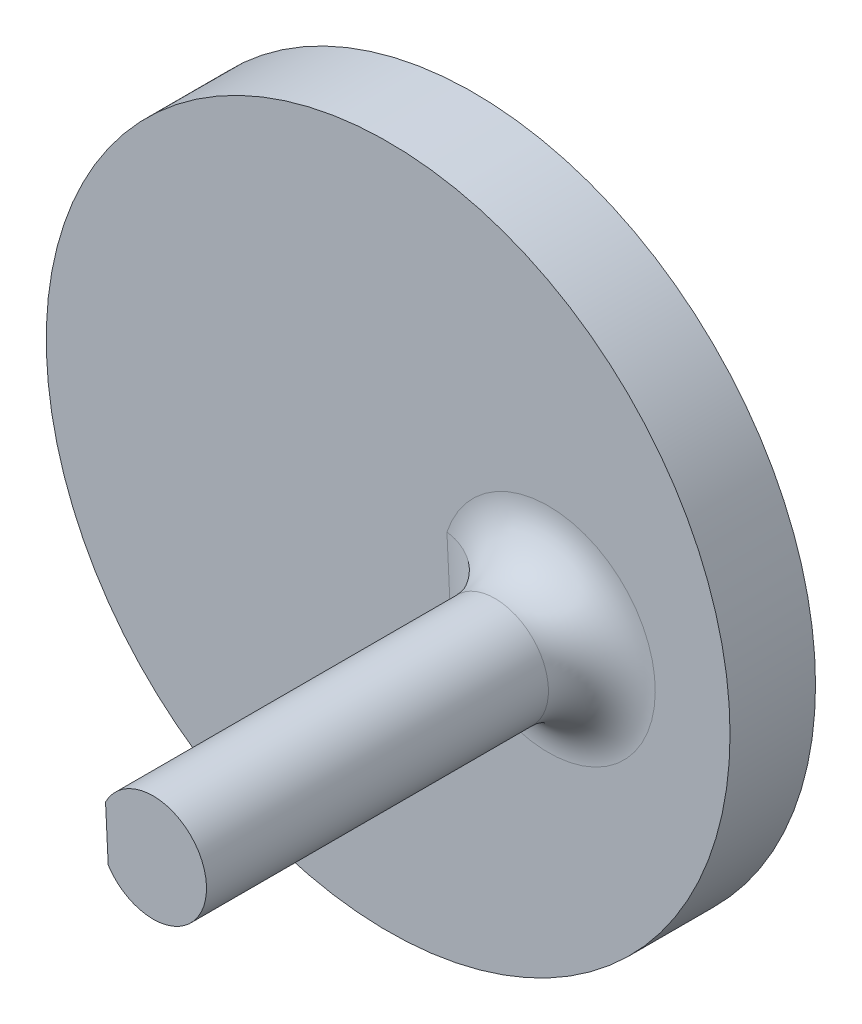
from build123d import *

# Parameters (mm, degrees)
ESQUISSE1_R             = 20.32
ESQUISSE1_R_2           = 3.175
BOSS_EXTRU_1_DEPTH      = 5.08
ESQUISSE2_R             = 3.175
BOSS_EXTRU_2_DEPTH      = 28.575
ENL_V_MAT_EXTRU_1_DEPTH = 23.495
ESQUISSE4_R             = 4.097809842
BOSS_EXTRU_3_DEPTH      = 5.08
ESQUISSE5_R             = 9.525
ESQUISSE5_R_2           = 3.175
BOSS_EXTRU_4_DEPTH      = 6.35
CONG_1_R                = 3.175


with BuildPart() as part:
    # Esquisse1 → Boss.-Extru.1 (new body)
    with BuildSketch(Plane.XY):
        Circle(ESQUISSE1_R)
        with Locations((9.525, 0)):
            Circle(ESQUISSE1_R_2, mode=Mode.SUBTRACT)
        Circle(ESQUISSE1_R_2, mode=Mode.SUBTRACT)
    extrude(amount=BOSS_EXTRU_1_DEPTH)

    # Esquisse2 → Boss.-Extru.2 (add)
    with BuildSketch(Plane.XY):
        with Locations((9.525, 0)):
            Circle(ESQUISSE2_R)
    extrude(amount=BOSS_EXTRU_2_DEPTH)

    # Esquisse3 → Enlèv. mat.-Extru.1 (cut)
    with BuildSketch(Plane.XY.offset(28.575)):
        Polygon((10.863482677, -81.610355532), (6.858308609, -1.723189492), (6.699328429, 1.447827743), (2.694154361, 81.334993784), (-157.08017772, 73.324645646), (-148.910849404, -89.620703669), align=None)
    extrude(amount=-ENL_V_MAT_EXTRU_1_DEPTH, mode=Mode.SUBTRACT)

    # Esquisse4 → Boss.-Extru.3 (add)
    with BuildSketch(Plane.XY.offset(5.08)):
        Circle(ESQUISSE4_R)
    extrude(amount=-BOSS_EXTRU_3_DEPTH)

    # Esquisse5 → Boss.-Extru.4 (add)
    with BuildSketch(Plane(origin=(0, 0, 0), x_dir=(-1, 0, 0), z_dir=(0, 0, -1))):
        Circle(ESQUISSE5_R)
        Circle(ESQUISSE5_R_2, mode=Mode.SUBTRACT)
    extrude(amount=BOSS_EXTRU_4_DEPTH)

    # Congé1
    cong_1_edges = [part.edges().sort_by_distance(p)[0] for p in [
        (12.696017235, 0.15898018, 5.08),
        (6.778818519, -0.137680874, 5.08),
        (9.525, 0, 0),
    ]]
    fillet(cong_1_edges, radius=CONG_1_R)


solid = part.part
